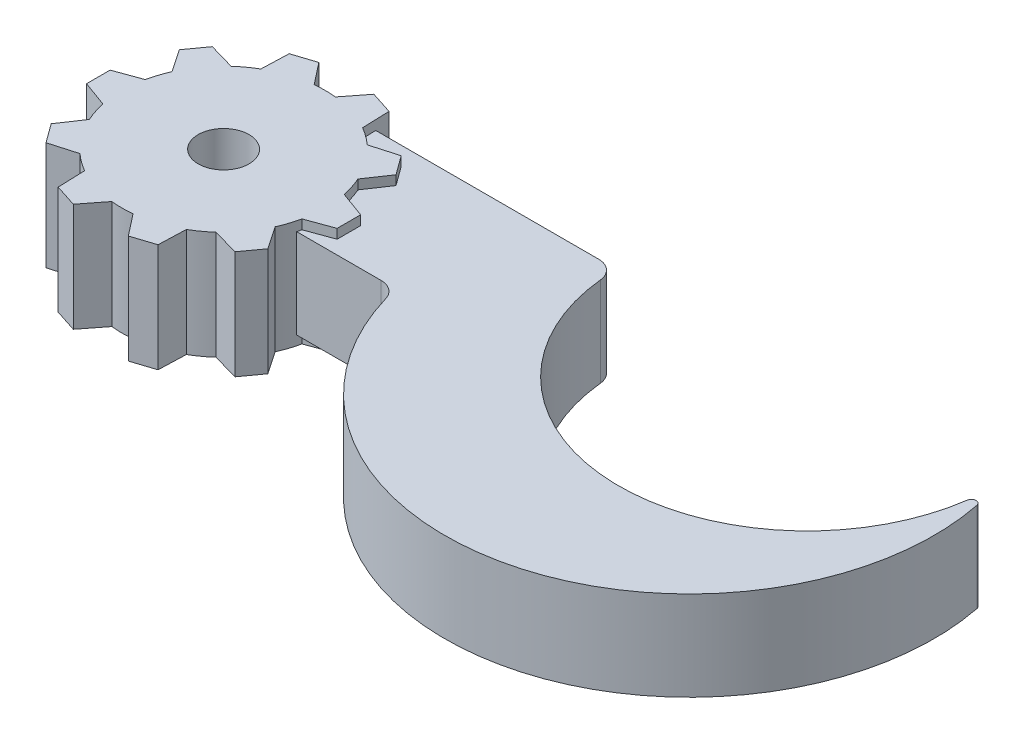
from build123d import *

# Parameters (mm, degrees)
CROQUIS1_R              = 10.8
CROQUIS1_R_2            = 2.7
SALIENTE_EXTRUIR1_DEPTH = 11.5
BOSS_EXTRUDE1_START     = 1
BOSS_EXTRUDE1_DEPTH     = 9.5


with BuildPart() as part:
    # Croquis1 → Saliente-Extruir1 (new body)
    with BuildSketch(Plane(origin=(0, 0, 0), x_dir=(1, 0, 0), z_dir=(0, 1, 0))):
        Circle(CROQUIS1_R)
        with Locations(Location((0, 0, 0), (0, 0, 270))):
            Circle(CROQUIS1_R_2, mode=Mode.SUBTRACT)
        with BuildLine():
            Line((13.3, 1.25), (10.563906891, 2.24585645))
            ThreePointArc((10.563906891, 2.24585645), (10.740814551, 1.129115932), (10.8, 0))
            ThreePointArc((10.8, 0), (10.740814551, -1.129115932), (10.563906891, -2.24585645))
            Line((10.563906891, -2.24585645), (13.3, -1.25))
            Line((13.3, -1.25), (13.3, 1.25))
        make_face()
        with BuildLine():
            Line((10.02519446, 8.828815098), (7.226298902, 8.026244712))
            ThreePointArc((7.226298902, 8.026244712), (8.737383539, 6.348080725), (9.866461502, 4.392372642))
            Line((9.866461502, 4.392372642), (11.494657591, 6.806272613))
            Line((11.494657591, 6.806272613), (10.02519446, 8.828815098))
        make_face()
        with BuildLine():
            Line((5.349828089, 10.8), (5.298746671, 12.262780424))
            Line((5.298746671, 12.262780424), (2.92110538, 13.03532291))
            Line((2.92110538, 13.03532291), (1.128490345, 10.740880296))
            ThreePointArc((1.128490345, 10.740880296), (3.337383539, 10.271410376), (5.400363168, 9.352864677))
            Line((5.400363168, 9.352864677), (5.349828089, 10.8))
        make_face()
        with BuildLine():
            ThreePointArc((-5.400363168, 9.352864677), (-3.337383539, 10.271410376), (-1.128490345, 10.740880296))
            Line((-1.128490345, 10.740880296), (-2.92110538, 13.03532291))
            Line((-2.92110538, 13.03532291), (-5.298746671, 12.262780424))
            Line((-5.298746671, 12.262780424), (-5.400363168, 9.352864677))
        make_face()
        with BuildLine():
            ThreePointArc((-9.866461502, 4.392372642), (-8.737383539, 6.348080725), (-7.226298902, 8.026244712))
            Line((-7.226298902, 8.026244712), (-10.02519446, 8.828815098))
            Line((-10.02519446, 8.828815098), (-11.494657591, 6.806272613))
            Line((-11.494657591, 6.806272613), (-9.866461502, 4.392372642))
        make_face()
        with BuildLine():
            ThreePointArc((-10.563906891, -2.24585645), (-10.8, 0), (-10.563906891, 2.24585645))
            Line((-10.563906891, 2.24585645), (-13.3, 1.25))
            Line((-13.3, 1.25), (-13.3, -1.25))
            Line((-13.3, -1.25), (-10.563906891, -2.24585645))
        make_face()
        with BuildLine():
            ThreePointArc((-7.226298902, -8.026244712), (-8.737383539, -6.348080725), (-9.866461502, -4.392372642))
            Line((-9.866461502, -4.392372642), (-11.494657591, -6.806272613))
            Line((-11.494657591, -6.806272613), (-10.02519446, -8.828815098))
            Line((-10.02519446, -8.828815098), (-7.226298902, -8.026244712))
        make_face()
        with BuildLine():
            ThreePointArc((-1.128490345, -10.740880296), (-3.337383539, -10.271410376), (-5.400363168, -9.352864677))
            Line((-5.400363168, -9.352864677), (-5.298746671, -12.262780424))
            Line((-5.298746671, -12.262780424), (-2.92110538, -13.03532291))
            Line((-2.92110538, -13.03532291), (-1.128490345, -10.740880296))
        make_face()
        with BuildLine():
            Line((5.298746671, -12.262780424), (5.400363168, -9.352864677))
            ThreePointArc((5.400363168, -9.352864677), (3.337383539, -10.271410376), (1.128490345, -10.740880296))
            Line((1.128490345, -10.740880296), (2.92110538, -13.03532291))
            Line((2.92110538, -13.03532291), (5.298746671, -12.262780424))
        make_face()
        with BuildLine():
            Line((11.494657591, -6.806272613), (9.866461502, -4.392372642))
            ThreePointArc((9.866461502, -4.392372642), (8.737383539, -6.348080725), (7.226298902, -8.026244712))
            Line((7.226298902, -8.026244712), (10.02519446, -8.828815098))
            Line((10.02519446, -8.828815098), (11.494657591, -6.806272613))
        make_face()
    extrude(amount=SALIENTE_EXTRUIR1_DEPTH)

    # Croquis1_6 → Boss-Extrude1 (add)
    with BuildSketch(Plane(origin=(0, 0, 0), x_dir=(1, 0, 0), z_dir=(0, 1, 0)).offset(BOSS_EXTRUDE1_START)):
        with BuildLine():
            Line((29.025420212, 10.8), (5.349828089, 10.8))
            Line((5.349828089, 10.8), (5.400363168, 9.352864677))
            ThreePointArc((5.400363168, 9.352864677), (6.348080725, 8.737383539), (7.226298902, 8.026244712))
            Line((7.226298902, 8.026244712), (10.02519446, 8.828815098))
            Line((10.02519446, 8.828815098), (11.494657591, 6.806272613))
            Line((11.494657591, 6.806272613), (9.866461502, 4.392372642))
            ThreePointArc((9.866461502, 4.392372642), (10.271410376, 3.337383539), (10.563906891, 2.24585645))
            Line((10.563906891, 2.24585645), (13.3, 1.25))
            Line((13.3, 1.25), (13.3, -1.25))
            Line((13.3, -1.25), (10.563906891, -2.24585645))
            ThreePointArc((10.563906891, -2.24585645), (10.512933542, -2.473505273), (10.457055035, -2.7))
            Line((10.457055035, -2.7), (19.42731544, -2.7))
            ThreePointArc((19.42731544, -2.7), (20.625475176, -3.098621454), (21.346022736, -4.135586754))
            ThreePointArc((21.346022736, -4.135586754), (52.452433734, -22.022808697), (71.724168494, 8.245355326))
            ThreePointArc((71.724168494, 8.245355326), (71.219997226, 8.647854219), (70.738687337, 8.218279059))
            ThreePointArc((70.738687337, 8.218279059), (50.52963152, -8.979070796), (31.015135616, 9.002565078))
            ThreePointArc((31.015135616, 9.002565078), (30.36610471, 10.284104133), (29.025420212, 10.8))
        make_face()
    extrude(amount=BOSS_EXTRUDE1_DEPTH)


solid = part.part
